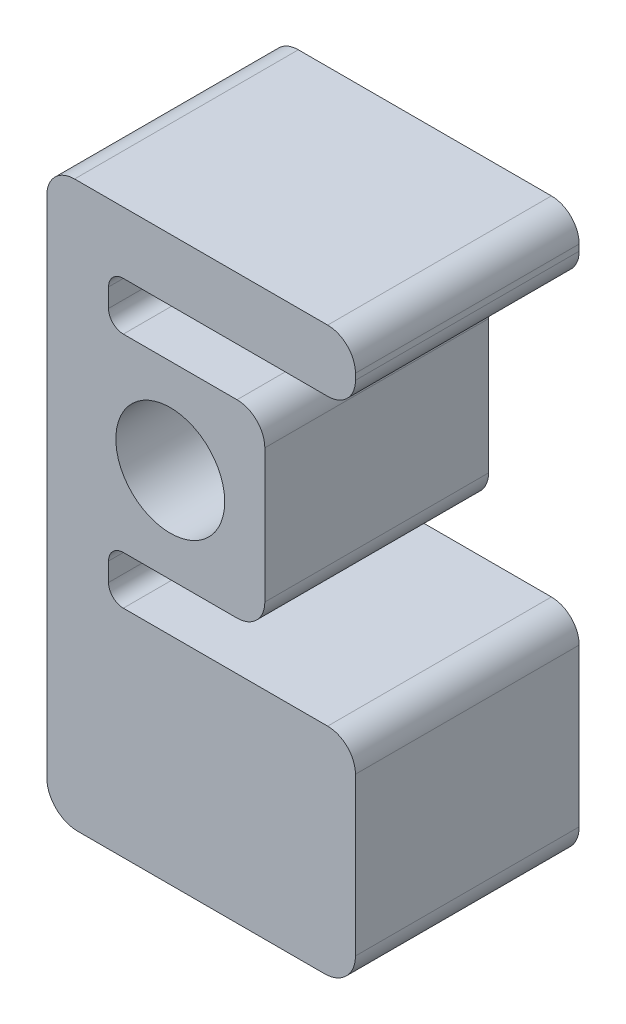
from build123d import *

# Parameters (mm, degrees)
SKETCH1_R           = 11.2
BOSS_EXTRUDE1_DEPTH = 46.0375


with BuildPart() as part:
    # Sketch1 → Boss-Extrude1 (new body)
    with BuildSketch(Plane.XY):
        with BuildLine():
            Line((-25.4, -67.479999962), (-25.4, 36.365))
            ThreePointArc((-25.4, 36.365), (-23.726115254, 40.406115254), (-19.685, 42.08))
            Line((-19.685, 42.08), (32.385, 42.08))
            ThreePointArc((32.385, 42.08), (36.426115254, 40.406115254), (38.1, 36.365))
            Line((38.1, 36.365), (38.1, 35.095))
            ThreePointArc((38.1, 35.095), (36.426115254, 31.053884746), (32.385, 29.38))
            Line((32.385, 29.38), (-9.652, 29.38))
            ThreePointArc((-9.652, 29.38), (-11.807261469, 28.487261469), (-12.7, 26.332))
            Line((-12.7, 26.332), (-12.7, 22.503))
            ThreePointArc((-12.7, 22.503), (-11.807261469, 20.347738531), (-9.652, 19.455))
            Line((-9.652, 19.455), (0, 19.455))
            Line((0, 19.455), (13.74, 19.455))
            ThreePointArc((13.74, 19.455), (17.781115254, 17.781115254), (19.455, 13.74))
            Line((19.455, 13.74), (19.455, 0))
            Line((19.455, 0), (19.455, -13.74))
            ThreePointArc((19.455, -13.74), (17.781115254, -17.781115254), (13.74, -19.455))
            Line((13.74, -19.455), (0, -19.455))
            Line((0, -19.455), (-9.652, -19.455))
            ThreePointArc((-9.652, -19.455), (-11.807261469, -20.347738531), (-12.7, -22.503))
            Line((-12.7, -22.503), (-12.7, -26.331999962))
            ThreePointArc((-12.7, -26.331999962), (-11.807261469, -28.487261431), (-9.652, -29.379999962))
            Line((-9.652, -29.379999962), (32.385, -29.379999962))
            ThreePointArc((32.385, -29.379999962), (36.426115254, -31.053884708), (38.1, -35.094999962))
            Line((38.1, -35.094999962), (38.1, -67.479999962))
            ThreePointArc((38.1, -67.479999962), (36.240128061, -71.970128023), (31.75, -73.829999962))
            Line((31.75, -73.829999962), (-19.05, -73.829999962))
            ThreePointArc((-19.05, -73.829999962), (-23.540128061, -71.970128023), (-25.4, -67.479999962))
        make_face()
        Circle(SKETCH1_R, mode=Mode.SUBTRACT)
    extrude(amount=BOSS_EXTRUDE1_DEPTH)


solid = part.part
